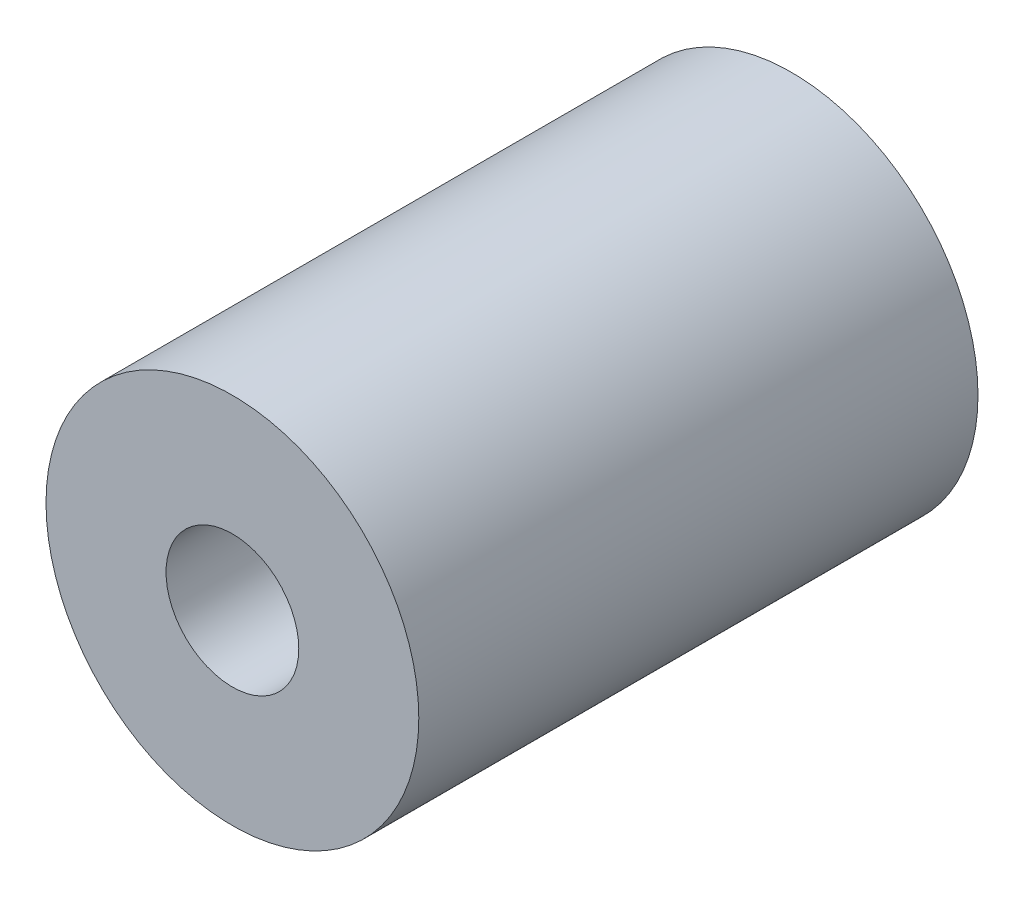
from build123d import *

# Parameters (mm, degrees)
FACE_2_R     = 3.175
FACE_2_R_2   = 1.1303
WASHER_DEPTH = 9.525


with BuildPart() as part:
    # face 2 → washer (new body)
    with BuildSketch(Plane.XY):
        Circle(FACE_2_R)
        Circle(FACE_2_R_2, mode=Mode.SUBTRACT)
    extrude(amount=-WASHER_DEPTH)


solid = part.part
